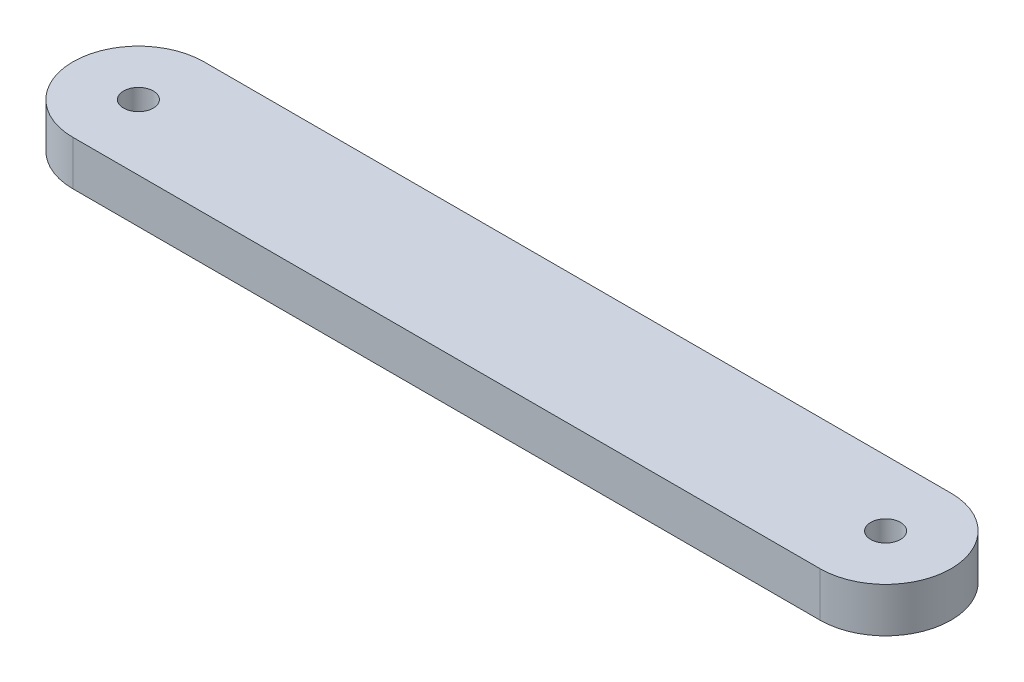
from build123d import *

# Parameters (mm, degrees)
SKETCH_1_R      = 0.5
EXTRUDE_1_DEPTH = 1.5


with BuildPart() as part:
    # 草图1 → 凸台-拉伸1 (new body)
    with BuildSketch(Plane(origin=(0, 0, 0), x_dir=(1, 0, 0), z_dir=(0, 1, 0))):
        with BuildLine():
            Line((-12.555, 2.2), (12.555, 2.2))
            ThreePointArc((12.555, 2.2), (14.755, 0), (12.555, -2.2))
            Line((12.555, -2.2), (-12.555, -2.2))
            ThreePointArc((-12.555, -2.2), (-14.755, 0), (-12.555, 2.2))
        make_face()
        with Locations((-12.555, 0)):
            Circle(SKETCH_1_R, mode=Mode.SUBTRACT)
        with Locations((12.555, 0)):
            Circle(SKETCH_1_R, mode=Mode.SUBTRACT)
    extrude(amount=EXTRUDE_1_DEPTH)


solid = part.part
